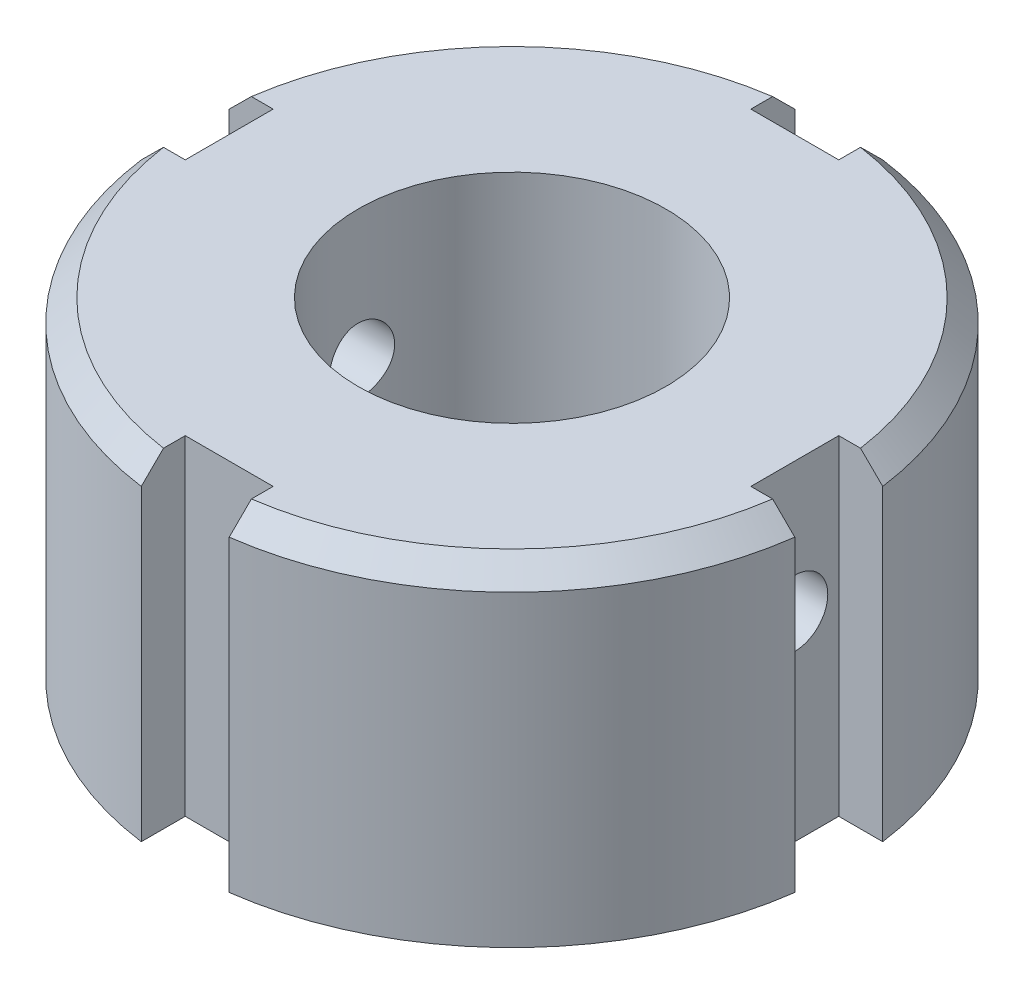
from build123d import *

# Parameters (mm, degrees)
SKETCH1_R               = 15
BOSS_EXTRUDE1_DEPTH     = 7.5
CUT_EXTRUDE1_DEPTH      = 8.5
CUT_EXTRUDE1_DEPTH_BACK = 8.5
CHAMFER1_SIZE           = 1
M16_TAPPED_HOLE1_D      = 14
M16_TAPPED_HOLE1_DEPTH  = 15
SKETCH5_R               = 1.5
CUT_EXTRUDE2_DEPTH      = 3
CUT_EXTRUDE2_DEPTH_BACK = 28.732137495


with BuildPart() as part:
    # Sketch1 → Boss-Extrude1 (new body, symmetric)
    with BuildSketch(Plane(origin=(0, 0, 0), x_dir=(1, 0, 0), z_dir=(0, 1, 0))):
        Circle(SKETCH1_R)
    extrude(amount=BOSS_EXTRUDE1_DEPTH, both=True)

    # Sketch2 → Cut-Extrude1 (cut, two sides)
    with BuildSketch(Plane(origin=(0, 0, 0), x_dir=(1, 0, 0), z_dir=(0, 1, 0))) as cut_extrude1_sk:
        with BuildLine():
            Line((-2, 14.866068747), (-2, 12.866068747))
            Line((-2, 12.866068747), (2, 12.866068747))
            Line((2, 12.866068747), (2, 14.866068747))
            ThreePointArc((2, 14.866068747), (0, 15), (-2, 14.866068747))
        make_face()
        with BuildLine():
            Line((14.866068747, 2), (12.866068747, 2))
            Line((12.866068747, 2), (12.866068747, -2))
            Line((12.866068747, -2), (14.866068747, -2))
            ThreePointArc((14.866068747, -2), (15, 0), (14.866068747, 2))
        make_face()
        with BuildLine():
            Line((2, -14.866068747), (2, -12.866068747))
            Line((2, -12.866068747), (-2, -12.866068747))
            Line((-2, -12.866068747), (-2, -14.866068747))
            ThreePointArc((-2, -14.866068747), (0, -15), (2, -14.866068747))
        make_face()
        with BuildLine():
            Line((-14.866068747, -2), (-12.866068747, -2))
            Line((-12.866068747, -2), (-12.866068747, 2))
            Line((-12.866068747, 2), (-14.866068747, 2))
            ThreePointArc((-14.866068747, 2), (-15, 0), (-14.866068747, -2))
        make_face()
    extrude(amount=CUT_EXTRUDE1_DEPTH, mode=Mode.SUBTRACT)
    extrude(cut_extrude1_sk.sketch, amount=-CUT_EXTRUDE1_DEPTH_BACK, mode=Mode.SUBTRACT)

    # Chamfer1
    chamfer1_edges = [part.edges().sort_by_distance(p)[0] for p in [
        (10.606601718, 7.5, -10.606601718),
        (-10.606601718, 7.5, -10.606601718),
        (-10.606601718, 7.5, 10.606601718),
        (10.606601718, 7.5, 10.606601718),
    ]]
    chamfer(chamfer1_edges, length=CHAMFER1_SIZE)

    # M16 Tapped Hole1
    with Locations(Plane(origin=(0, 7.5, 0), x_dir=(1, 0, 0), z_dir=(0, 1, 0))):
        with Locations((0, 0)):
            Hole(M16_TAPPED_HOLE1_D / 2, depth=M16_TAPPED_HOLE1_DEPTH)

    # Sketch5 → Cut-Extrude2 (cut, two sides)
    with BuildSketch(Plane(origin=(12.866068747, 0, 0), x_dir=(0, 0, -1), z_dir=(1, 0, 0))) as cut_extrude2_sk:
        with Locations((0, 1.5)):
            Circle(SKETCH5_R)
    extrude(amount=CUT_EXTRUDE2_DEPTH, mode=Mode.SUBTRACT)
    extrude(cut_extrude2_sk.sketch, amount=-CUT_EXTRUDE2_DEPTH_BACK, mode=Mode.SUBTRACT)


solid = part.part
